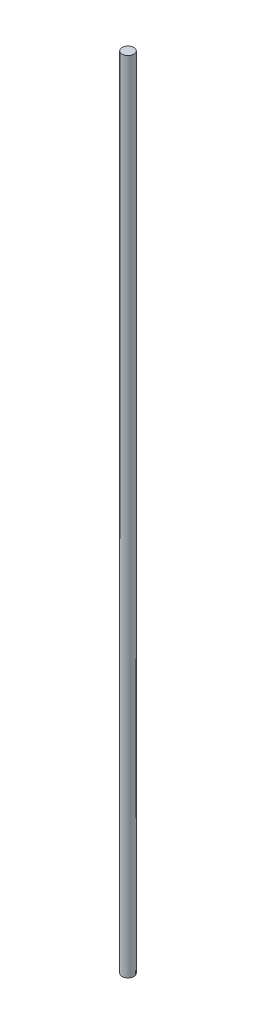
from build123d import *

# Parameters (mm, degrees)
SKETCH6_R           = 0.3175
BOSS_EXTRUDE1_DEPTH = 43.18


with BuildPart() as part:
    # Sketch6 → Boss-Extrude1 (new body)
    with BuildSketch(Plane(origin=(0, 16.51, 0), x_dir=(1, 0, 0), z_dir=(0, 1, 0))):
        with Locations((0, 0.693610213)):
            Circle(SKETCH6_R)
    extrude(amount=BOSS_EXTRUDE1_DEPTH)


solid = part.part
